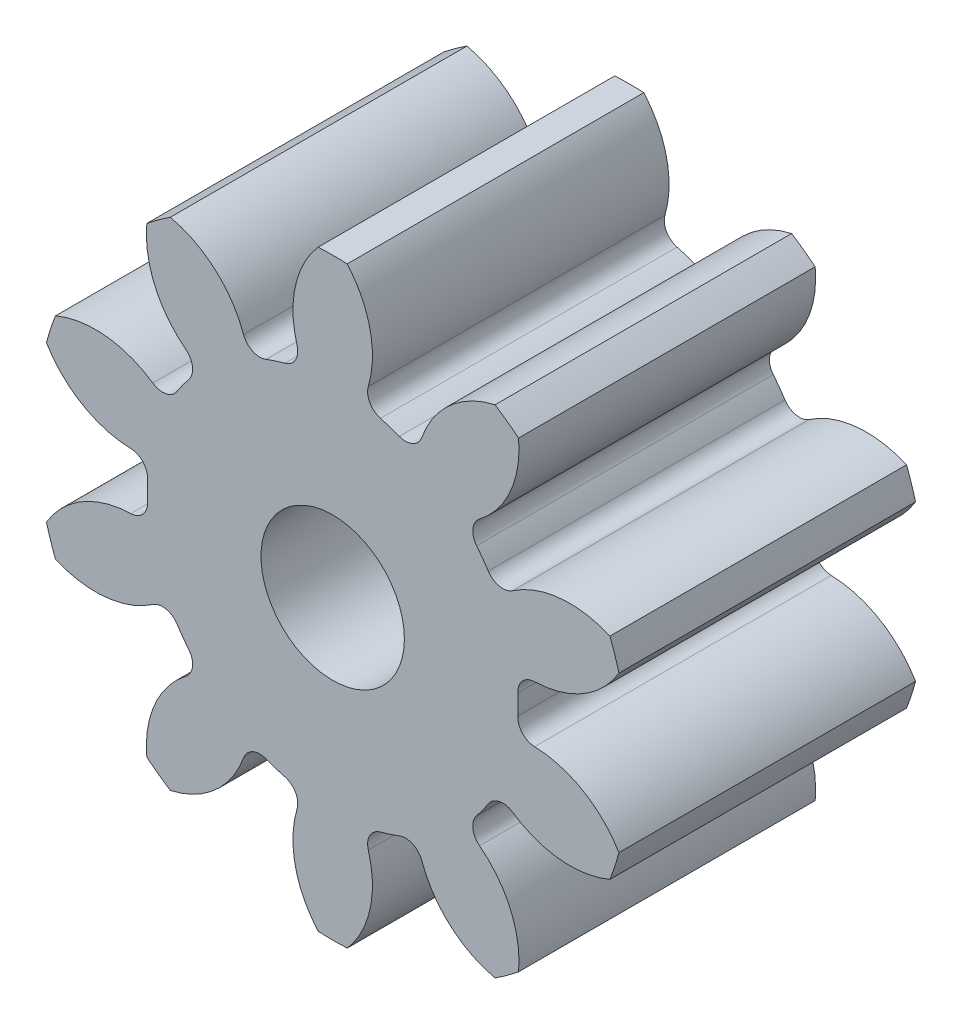
from build123d import *

# Parameters (mm, degrees)
BOSS_EXTRU_1_DEPTH                 = 6
CONG_1_R                           = 0.35
R_P_TITION_CIRCULAIRE4_COUNT       = 10
CONG_1_OF_R_P_TITION_CIRCULAIRE4_R = 0.35
ESQUISSE5_R                        = 1.45
ENL_V_MAT_EXTRU_1_DEPTH            = 7.0000001


with BuildPart() as part:
    # Esquisse3 → Boss.-Extru.1 (new body)
    with BuildSketch(Plane.XY):
        with BuildLine():
            Line((-2.537520642, 3.006109478), (-1.378706913, -0.560352459))
            Line((-1.378706913, -0.560352459), (-0.219893184, 3.006109478))
            ThreePointArc((-0.219893184, 3.006109478), (-0.507143954, 3.086958607), (-0.799913822, 3.144711449))
            ThreePointArc((-0.799913822, 3.144711449), (-0.590327271, 4.33245583), (-1.084967982, 5.432453015))
            ThreePointArc((-1.084967982, 5.432453015), (-1.378706913, 5.439647541), (-1.672445844, 5.432453015))
            ThreePointArc((-1.672445844, 5.432453015), (-2.167086555, 4.33245583), (-1.957500004, 3.144711449))
            ThreePointArc((-1.957500004, 3.144711449), (-2.250269872, 3.086958607), (-2.537520642, 3.006109478))
        make_face()
    boss_extru_1 = extrude(amount=BOSS_EXTRU_1_DEPTH)

    # Cong_1
    cong_1_edges = [part.edges().sort_by_distance(p)[0] for p in [
        (-1.957500004, 3.144711449, 3),
        (-0.799913822, 3.144711449, 3),
    ]]
    fillet(cong_1_edges, radius=CONG_1_R)

    # R_p_tition circulaire4: Boss.-Extru.1 ×10 about axis
    r_p_tition_circulaire4_axis = Axis((-1.378706913, -0.560352459, 0), (0, 0, 1))
    for i in range(1, R_P_TITION_CIRCULAIRE4_COUNT):
        add(boss_extru_1.rotate(r_p_tition_circulaire4_axis, i * 360 / R_P_TITION_CIRCULAIRE4_COUNT))

    # Cong_1 of R_p_tition circulaire4
    cong_1_of_r_p_tition_circulaire4_edges = [part.edges().sort_by_distance(p)[0] for p in [
        (-4.024742284, 2.096901165, 3),
        (-3.08823539, 2.777313251, 3),
        (-5.081288987, 0.034110313, 3),
        (-4.723575184, 1.135040195, 3),
        (-4.723575184, -2.255745112, 3),
        (-5.081288987, -1.15481523, 3),
        (-3.08823539, -3.898018168, 3),
        (-4.024742284, -3.217606082, 3),
        (-0.799913822, -4.265416366, 3),
        (-1.957500004, -4.265416366, 3),
        (1.267328457, -3.217606082, 3),
        (0.330821563, -3.898018168, 3),
        (2.323875161, -1.15481523, 3),
        (1.966161358, -2.255745112, 3),
        (1.966161358, 1.135040195, 3),
        (2.323875161, 0.034110313, 3),
        (0.330821563, 2.777313251, 3),
        (1.267328457, 2.096901165, 3),
    ]]
    fillet(cong_1_of_r_p_tition_circulaire4_edges, radius=CONG_1_OF_R_P_TITION_CIRCULAIRE4_R)

    # Esquisse5 → Enl_v. mat.-Extru.1 (cut, through all)
    with BuildSketch(Plane.XY.offset(6)):
        with Locations((-1.378706913, -0.560352459)):
            Circle(ESQUISSE5_R)
    extrude(amount=-ENL_V_MAT_EXTRU_1_DEPTH, mode=Mode.SUBTRACT)


solid = part.part
